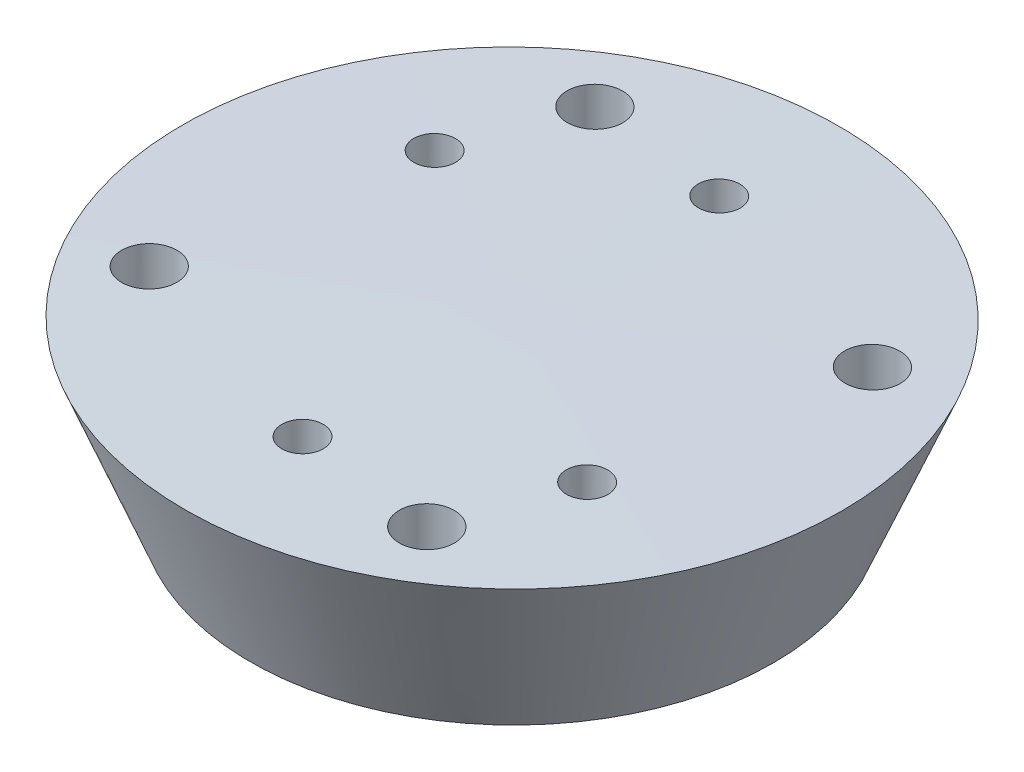
from build123d import *

# Parameters (mm, degrees)
SCHIZZO2_R                    = 2.5
TAGLIO_ESTRUSIONE1_DEPTH      = 21
TAGLIO_ESTRUSIONE1_DEPTH_BACK = 10
TAGLIO_ESTRUSIONE2_DEPTH      = 11


with BuildPart() as part:
    # Schizzo1 → Rivoluzione1 (revolve)
    with BuildSketch(Plane.XY):
        Polygon((0, -101.5), (0.147426206, -81.5), (-39.399917748, -81.5), (-31.5, -101.5), align=None)
    revolve(axis=Axis((0, -101.5, 0), (0.00737111, 0.999972833, 0)))

    # Schizzo2 → Taglio-Estrusione1 (cut, two sides)
    with BuildSketch(Plane(origin=(0, -101.5, 0), x_dir=(1, 0, 0), z_dir=(0, 1, 0))) as taglio_estrusione1_sk:
        with Locations((21.650635095, -12.5)):
            Circle(SCHIZZO2_R)
        with Locations((0, -25)):
            Circle(SCHIZZO2_R)
        with Locations((-21.650635095, 12.5)):
            Circle(SCHIZZO2_R)
        with Locations((0, 25)):
            Circle(SCHIZZO2_R)
    extrude(amount=TAGLIO_ESTRUSIONE1_DEPTH, mode=Mode.SUBTRACT)
    extrude(taglio_estrusione1_sk.sketch, amount=-TAGLIO_ESTRUSIONE1_DEPTH_BACK, mode=Mode.SUBTRACT)

    # Schizzo3 → Taglio-Estrusione2 (cut)
    with BuildSketch(Plane.XZ.offset(81.5)):
        with BuildLine():
            ThreePointArc((17.404264159, 23.501763124), (19.888877198, 27.491500276), (15.899140045, 29.976113315))
            ThreePointArc((15.899140045, 29.976113315), (13.414527007, 25.986376162), (17.404264159, 23.501763124))
        make_face()
        with BuildLine():
            ThreePointArc((29.976113315, -15.899140045), (25.986376162, -13.414527007), (23.501763124, -17.404264159))
            ThreePointArc((23.501763124, -17.404264159), (27.491500276, -19.888877198), (29.976113315, -15.899140045))
        make_face()
        with BuildLine():
            ThreePointArc((-15.899140045, -29.976113315), (-13.414527007, -25.986376162), (-17.404264159, -23.501763124))
            ThreePointArc((-17.404264159, -23.501763124), (-19.888877198, -27.491500276), (-15.899140045, -29.976113315))
        make_face()
        with BuildLine():
            ThreePointArc((-29.976113315, 15.899140045), (-25.986376162, 13.414527007), (-23.501763124, 17.404264159))
            ThreePointArc((-23.501763124, 17.404264159), (-27.491500276, 19.888877198), (-29.976113315, 15.899140045))
        make_face()
    extrude(amount=TAGLIO_ESTRUSIONE2_DEPTH, mode=Mode.SUBTRACT)


solid = part.part
